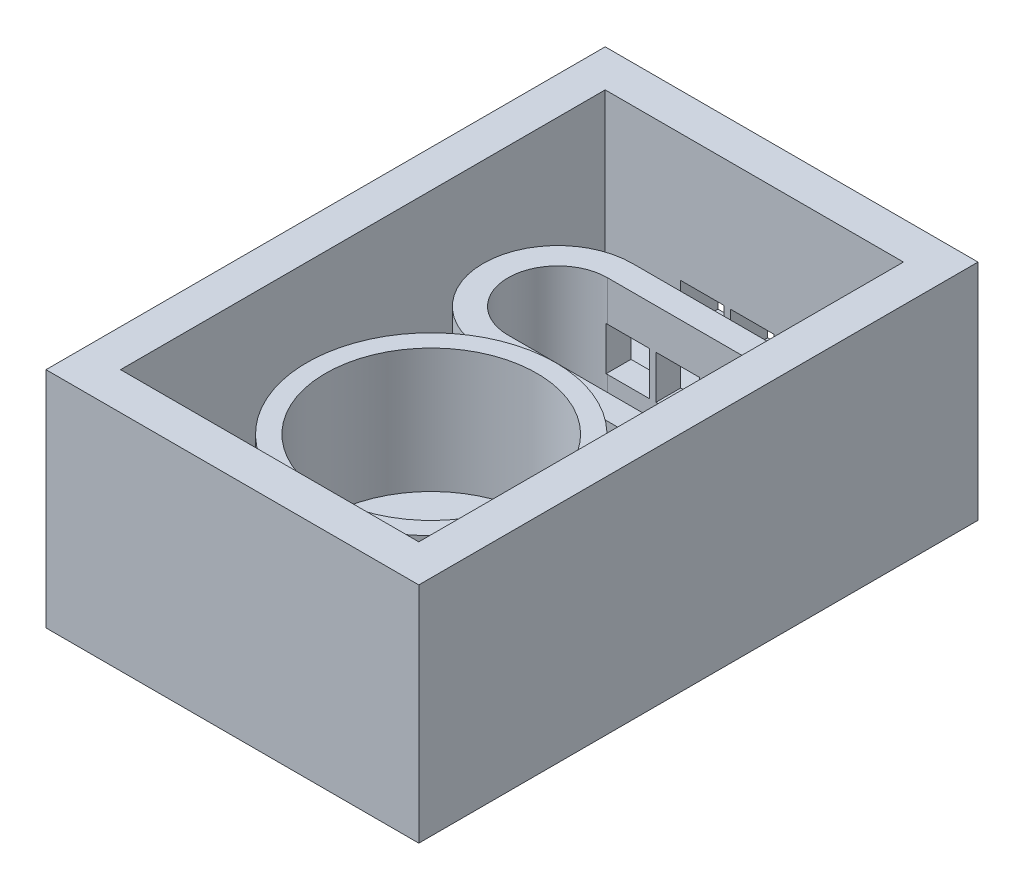
from build123d import *

# Parameters (mm, degrees)
SKETCH1_W               = 30
SKETCH1_H               = 45
SKETCH1_W_2             = 24
SKETCH1_H_2             = 39
BOSS_EXTRUDE4_DEPTH     = 10
SKETCH1_R               = 10
SKETCH1_R_2             = 8.5
BOSS_EXTRUDE4_2_DEPTH   = 10
SKETCH1_5_W             = 30
SKETCH1_5_H             = 45
SKETCH1_5_W_2           = 24
SKETCH1_5_H_2           = 39
BOSS_EXTRUDE5_DEPTH     = 15
SKETCH3_W               = 30
SKETCH3_H               = 45
BOSS_EXTRUDE6_DEPTH     = 3
BOSS_EXTRUDE9_DEPTH     = 8
CUT_EXTRUDE2_DEPTH      = 11
CUT_EXTRUDE2_DEPTH_BACK = 8
SKETCH6_W               = 3.5
SKETCH6_H               = 3.5


with BuildPart() as part:
    # Sketch1 → Boss-Extrude4 (new body)
    with BuildSketch(Plane(origin=(0, 0, 0), x_dir=(1, 0, 0), z_dir=(0, 1, 0))):
        with Locations((0, 6.5)):
            Rectangle(SKETCH1_W, SKETCH1_H)
        with Locations((0, 6.5)):
            Rectangle(SKETCH1_W_2, SKETCH1_H_2, mode=Mode.SUBTRACT)
    extrude(amount=BOSS_EXTRUDE4_DEPTH)

    # Sketch1_5 → Boss-Extrude5 (add)
    with BuildSketch(Plane(origin=(0, 0, 0), x_dir=(1, 0, 0), z_dir=(0, 1, 0))):
        with Locations((0, 6.5)):
            Rectangle(SKETCH1_5_W, SKETCH1_5_H)
        with Locations((0, 6.5)):
            Rectangle(SKETCH1_5_W_2, SKETCH1_5_H_2, mode=Mode.SUBTRACT)
    extrude(amount=BOSS_EXTRUDE5_DEPTH)



with BuildPart() as body_2:
    # Sketch1 → Boss-Extrude4 2 (new body)
    with BuildSketch(Plane(origin=(0, 0, 0), x_dir=(1, 0, 0), z_dir=(0, 1, 0))):
        Circle(SKETCH1_R)
        Circle(SKETCH1_R_2, mode=Mode.SUBTRACT)
    extrude(amount=BOSS_EXTRUDE4_2_DEPTH)


with BuildPart() as part_1:
    add(part.part)

    add(body_2.part)  # Boss-Extrude6 merges body 2
    # Sketch3 → Boss-Extrude6 (add)
    with BuildSketch(Plane.XZ):
        with Locations((0, -6.5)):
            Rectangle(SKETCH3_W, SKETCH3_H)
    extrude(amount=BOSS_EXTRUDE6_DEPTH)


with BuildPart() as body_2_2:
    # Sketch4 → Boss-Extrude9 (new body)
    with BuildSketch(Plane(origin=(0, 0, 0), x_dir=(1, 0, 0), z_dir=(0, 1, 0))):
        with BuildLine():
            Line((-5.815986723, 22), (5.576152219, 22))
            ThreePointArc((5.576152219, 22), (11.576152219, 16), (5.576152219, 10))
            Line((5.576152219, 10), (-5.815986723, 10))
            ThreePointArc((-5.815986723, 10), (-11.815986723, 16), (-5.815986723, 22))
        make_face()
        with BuildLine():
            Line((-5.815986723, 20), (5.576152219, 20))
            ThreePointArc((5.576152219, 20), (9.576152219, 16), (5.576152219, 12))
            Line((5.576152219, 12), (-5.815986723, 12))
            ThreePointArc((-5.815986723, 12), (-9.815986723, 16), (-5.815986723, 20))
        make_face(mode=Mode.SUBTRACT)
    extrude(amount=BOSS_EXTRUDE9_DEPTH)


with BuildPart() as cut_extrude2_tool:
    # Sketch6 → Cut-Extrude2 (new, two sides: drawn at the far end of the back side and taken through both)
    with BuildSketch(Plane.XY.offset(-26).offset(-CUT_EXTRUDE2_DEPTH_BACK)):
        with Locations((3.826152219, 3.007864186)):
            Rectangle(SKETCH6_W, SKETCH6_H)
        with Locations((-0.173847781, 3.007864186)):
            Rectangle(SKETCH6_W, SKETCH6_H)
        with Locations((-4.173847781, 3.007864186)):
            Rectangle(SKETCH6_W, SKETCH6_H)
    extrude(amount=CUT_EXTRUDE2_DEPTH + CUT_EXTRUDE2_DEPTH_BACK)


with BuildPart() as part_2:
    add(part_1.part)

    # Cut-Extrude2: cut by cut_extrude2_tool
    add(cut_extrude2_tool.part, mode=Mode.SUBTRACT)


with BuildPart() as body_2_2_1:
    add(body_2_2.part)

    # Cut-Extrude2: cut by cut_extrude2_tool
    add(cut_extrude2_tool.part, mode=Mode.SUBTRACT)


solid = Compound([part_2.part, body_2_2_1.part])
